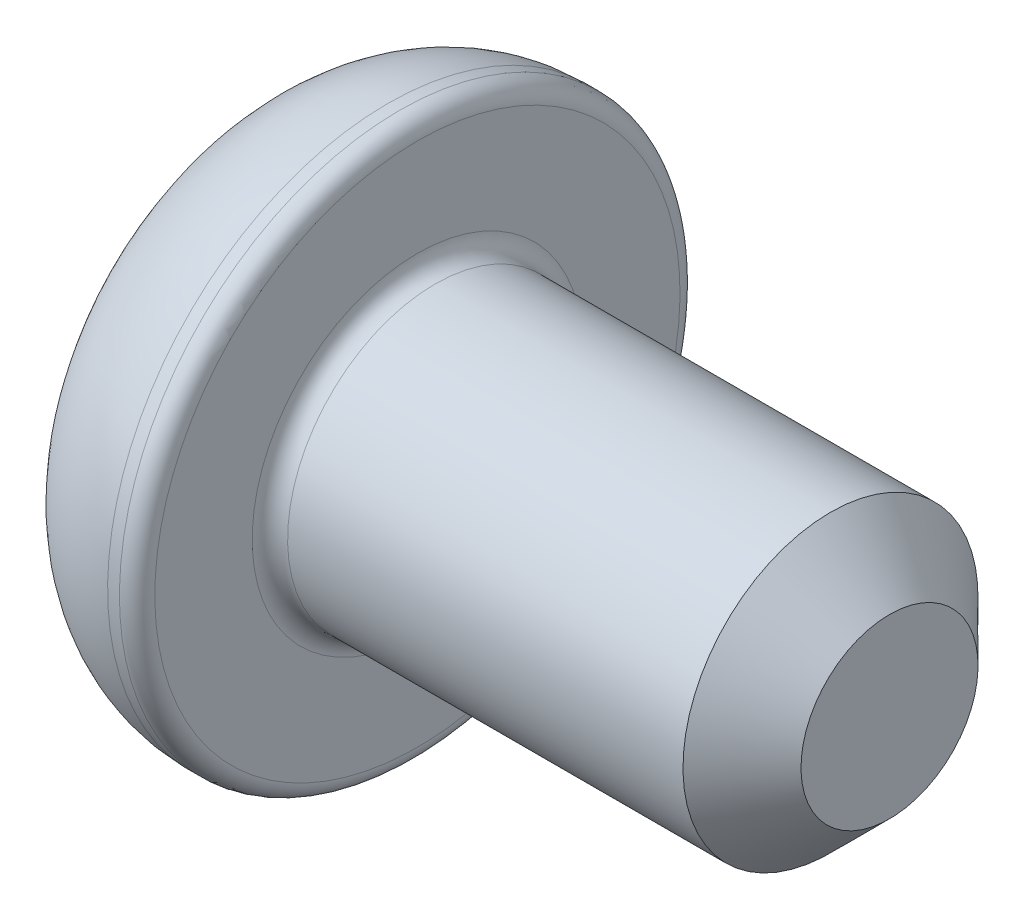
from build123d import *

# Parameters (mm, degrees)
CUT_EXTRUDE_1_DEPTH = 1.5
FILLET_1_R          = 0.3
CHAMFER_1_SIZE      = 1


with BuildPart() as part:
    # Эскиз1 → Повернуть1 (revolve)
    with BuildSketch(Plane.XY):
        with BuildLine():
            Line((0, 0), (0, 3.625))
            ThreePointArc((0, 3.625), (0.908821487, 4.451033224), (2.1, 4.75))
            Line((2.1, 4.75), (2.6, 4.75))
            Line((2.6, 4.75), (2.6, 2.5))
            Line((2.6, 2.5), (10.6, 2.5))
            Line((10.6, 2.5), (10.6, 0))
            Line((10.6, 0), (0, 0))
        make_face()
    revolve(axis=Axis((10.6, 0, 0), (-1, 0, 0)))

    # Эскиз2 → Вырез-Вытянуть1 (cut)
    with BuildSketch(Plane.ZY):
        Polygon((0.866025404, 1.5), (-0.866025404, 1.5), (-1.732050808, 0), (-0.866025404, -1.5), (0.866025404, -1.5), (1.732050808, 0), align=None)
    extrude(amount=-CUT_EXTRUDE_1_DEPTH, mode=Mode.SUBTRACT)

    # Скругление1
    fillet_1_edges = [part.edges().sort_by_distance(p)[0] for p in [
        (2.6, -2.5, 0),
        (2.6, -4.75, 0),
    ]]
    fillet(fillet_1_edges, radius=FILLET_1_R)

    # Фаска1
    chamfer_1_edges = [part.edges().sort_by_distance(p)[0] for p in [
        (10.6, -2.5, 0),
    ]]
    chamfer(chamfer_1_edges, length=CHAMFER_1_SIZE)


solid = part.part
